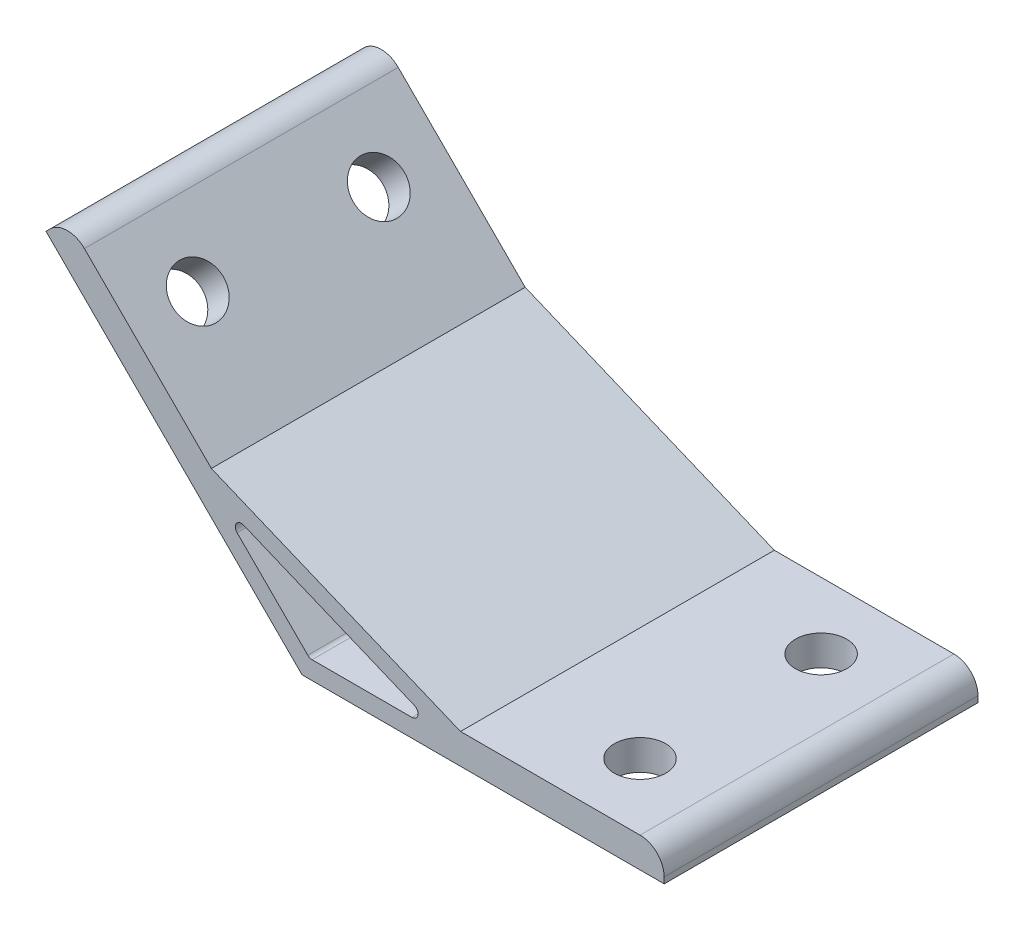
from build123d import *

# Parameters (mm, degrees)
EXTRUDE_1_DEPTH     = 26
SKETCH_2_R          = 4.25
CUT_EXTRUDE_1_DEPTH = 5
SKETCH_3_R          = 4.25
CUT_EXTRUDE_2_DEPTH = 5
FILLET_1_R          = 4
FILLET_2_R          = 1


with BuildPart() as part:
    # Эскиз1 → Бобышка-Вытянуть1 (new body, symmetric)
    with BuildSketch(Plane.XY):
        Polygon((0, 0), (-42.426406871, 42.426406871), (-38.890872965, 45.961940777), (-15.028558569, 22.099626381), (26.253591352, 5), (60, 5), (60, 0), align=None)
        Polygon((-14.313708499, 18.556349186), (23.242640687, 3), (1.242640687, 3), align=None, mode=Mode.SUBTRACT)
    extrude(amount=EXTRUDE_1_DEPTH, both=True)

    # Эскиз2 → Вырез-Вытянуть1 (cut)
    with BuildSketch(Plane(origin=(0, 0, 0), x_dir=(0, 0, 1), z_dir=(-0.707106781, -0.707106781, 0))):
        with Locations(Location((-15, 45, 0), (0, 0, 270))):  # turned: the seam where the file's is
            Circle(SKETCH_2_R)
        with Locations(Location((15, 45, 0), (0, 0, 270))):  # turned: the seam where the file's is
            Circle(SKETCH_2_R)
    extrude(amount=-CUT_EXTRUDE_1_DEPTH, mode=Mode.SUBTRACT)

    # Эскиз3 → Вырез-Вытянуть2 (cut)
    with BuildSketch(Plane.XZ):
        with Locations(Location((45, 15, 0), (0, 0, 270))):  # turned: the seam where the file's is
            Circle(SKETCH_3_R)
        with Locations(Location((45, -15, 0), (0, 0, 270))):  # turned: the seam where the file's is
            Circle(SKETCH_3_R)
    extrude(amount=-CUT_EXTRUDE_2_DEPTH, mode=Mode.SUBTRACT)

    # Скругление1
    fillet_1_edges = [part.edges().sort_by_distance(p)[0] for p in [
        (-38.890872965, 45.961940777, 0),
        (60, 5, 0),
    ]]
    fillet(fillet_1_edges, radius=FILLET_1_R)

    # Скругление2
    fillet_2_edges = [part.edges().sort_by_distance(p)[0] for p in [
        (-14.313708499, 18.556349186, 0),
        (1.242640687, 3, 0),
        (23.242640687, 3, 0),
    ]]
    fillet(fillet_2_edges, radius=FILLET_2_R)


solid = part.part
